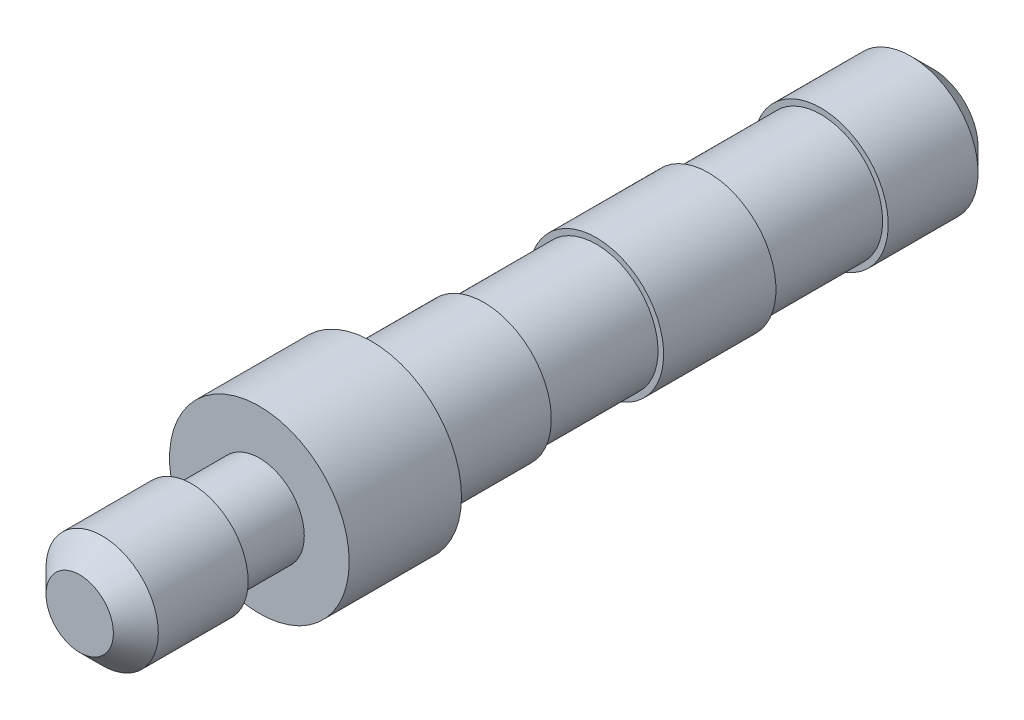
from build123d import *

# Parameters (mm, degrees)
ESQUISSE1_R         = 4
BOSS_EXTRU_1_DEPTH  = 5
ESQUISSE5_R         = 3
BOSS_EXTRU_5_DEPTH  = 5
ESQUISSE6_R         = 2.75
BOSS_EXTRU_6_DEPTH  = 5
ESQUISSE7_R         = 3
BOSS_EXTRU_7_DEPTH  = 5
ESQUISSE8_R         = 2.75
BOSS_EXTRU_8_DEPTH  = 5
ESQUISSE9_R         = 3
BOSS_EXTRU_9_DEPTH  = 5
CHANFREIN1_SIZE     = 1
ESQUISSE10_R        = 2
BOSS_EXTRU_10_DEPTH = 3
ESQUISSE11_R        = 2.5
BOSS_EXTRU_11_DEPTH = 5
CHANFREIN2_SIZE     = 1


with BuildPart() as part:
    # Esquisse1 → Boss.-Extru.1 (new body)
    with BuildSketch(Plane.XY):
        Circle(ESQUISSE1_R)
    extrude(amount=BOSS_EXTRU_1_DEPTH)

    # Esquisse5 → Boss.-Extru.5 (add)
    with BuildSketch(Plane(origin=(0, 0, 0), x_dir=(-1, 0, 0), z_dir=(0, 0, -1))):
        Circle(ESQUISSE5_R)
    extrude(amount=BOSS_EXTRU_5_DEPTH)

    # Esquisse6 → Boss.-Extru.6 (add)
    with BuildSketch(Plane(origin=(0, 0, -5), x_dir=(-1, 0, 0), z_dir=(0, 0, -1))):
        Circle(ESQUISSE6_R)
    extrude(amount=BOSS_EXTRU_6_DEPTH)

    # Esquisse7 → Boss.-Extru.7 (add)
    with BuildSketch(Plane(origin=(0, 0, -10), x_dir=(-1, 0, 0), z_dir=(0, 0, -1))):
        Circle(ESQUISSE7_R)
    extrude(amount=BOSS_EXTRU_7_DEPTH)

    # Esquisse8 → Boss.-Extru.8 (add)
    with BuildSketch(Plane(origin=(0, 0, -15), x_dir=(-1, 0, 0), z_dir=(0, 0, -1))):
        Circle(ESQUISSE8_R)
    extrude(amount=BOSS_EXTRU_8_DEPTH)

    # Esquisse9 → Boss.-Extru.9 (add)
    with BuildSketch(Plane(origin=(0, 0, -20), x_dir=(-1, 0, 0), z_dir=(0, 0, -1))):
        Circle(ESQUISSE9_R)
    extrude(amount=BOSS_EXTRU_9_DEPTH)

    # Chanfrein1
    chanfrein1_edges = [part.edges().sort_by_distance(p)[0] for p in [
        (3, 0, -25),
    ]]
    chamfer(chanfrein1_edges, length=CHANFREIN1_SIZE)

    # Esquisse10 → Boss.-Extru.10 (add)
    with BuildSketch(Plane.XY.offset(5)):
        Circle(ESQUISSE10_R)
    extrude(amount=BOSS_EXTRU_10_DEPTH)

    # Esquisse11 → Boss.-Extru.11 (add)
    with BuildSketch(Plane.XY.offset(8)):
        Circle(ESQUISSE11_R)
    extrude(amount=BOSS_EXTRU_11_DEPTH)

    # Chanfrein2
    chanfrein2_edges = [part.edges().sort_by_distance(p)[0] for p in [
        (-2.5, 0, 13),
    ]]
    chamfer(chanfrein2_edges, length=CHANFREIN2_SIZE)


solid = part.part
